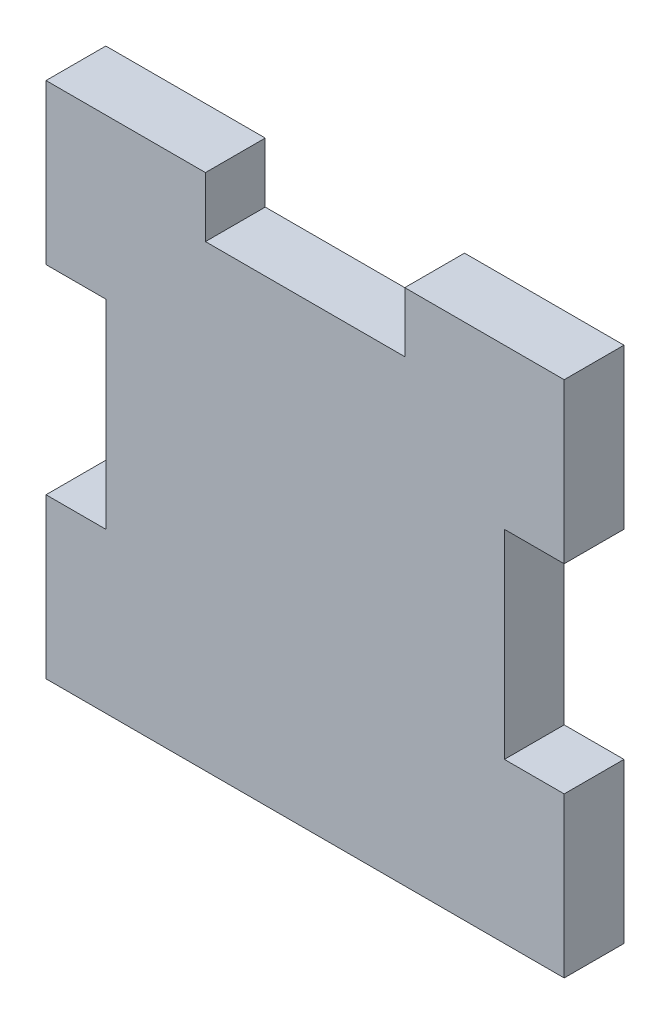
from build123d import *

# Parameters (mm, degrees)
BOSS_EXTRUDE1_DEPTH = 3


with BuildPart() as part:
    # Sketch1 → Boss-Extrude1 (new body)
    with BuildSketch(Plane.XY):
        Polygon((0, 18), (0, 26), (8, 26), (8, 23), (18, 23), (18, 26), (26, 26), (26, 18), (23, 18), (23, 8), (26, 8), (26, 0), (0, 0), (0, 8), (3, 8), (3, 18), align=None)
    extrude(amount=BOSS_EXTRUDE1_DEPTH)


solid = part.part
